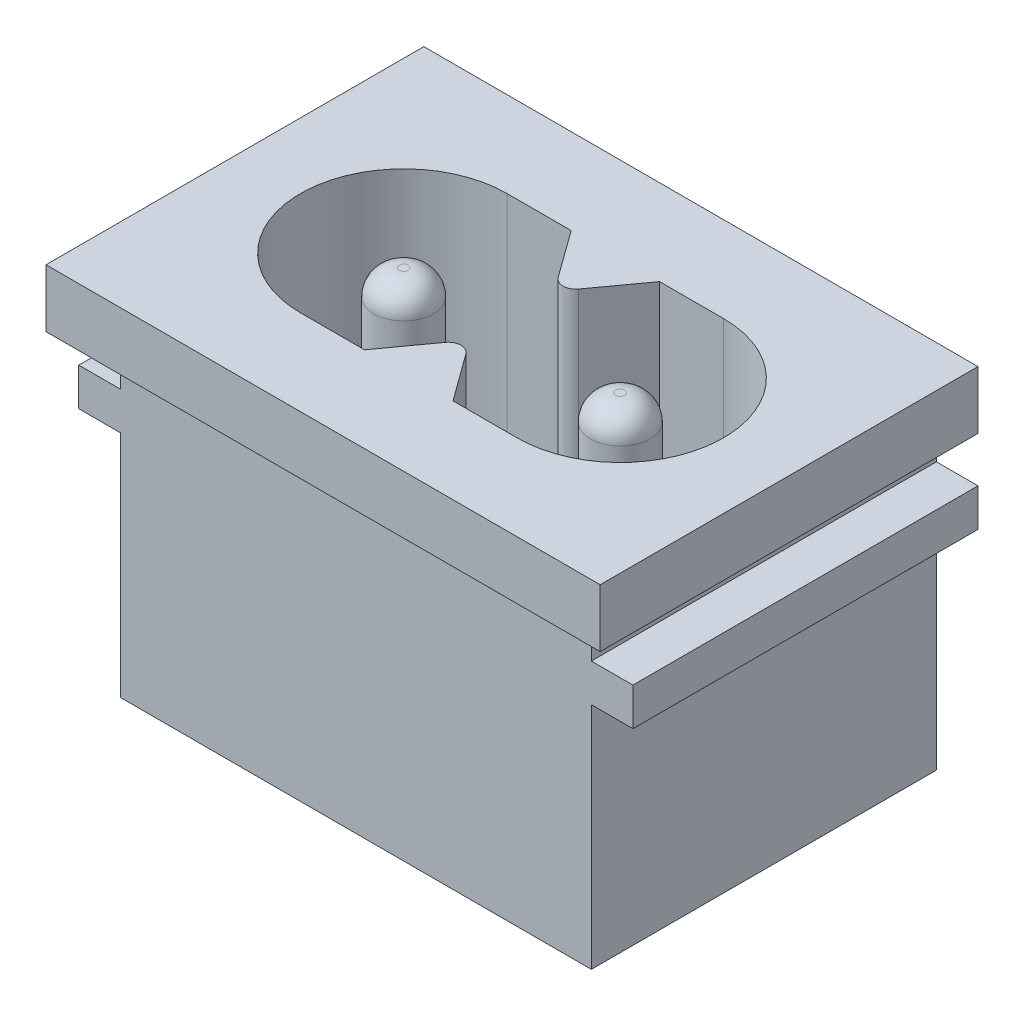
from build123d import *

# Parameters (mm, degrees)
SKETCH_1_W          = 22
SKETCH_1_H          = 15
EXTRUDE_1_DEPTH     = 2.3
SKETCH_2_W          = 18.7
SKETCH_2_H          = 13.7
EXTRUDE_2_DEPTH     = 12.4
SKETCH_3_W          = 13.7
SKETCH_3_H          = 1.5
EXTRUDE_3_DEPTH     = 1.65
SKETCH_4_W          = 13.7
SKETCH_4_H          = 1.5
EXTRUDE_4_DEPTH     = 1.65
CUT_EXTRUDE_1_DEPTH = 10
SKETCH_5_R          = 1.18
EXTRUDE_5_DEPTH     = 9.5
FILLET_6_R          = 1


with BuildPart() as part:
    # 草图1 → 凸台-拉伸1 (new body)
    with BuildSketch(Plane(origin=(0, 0, 0), x_dir=(1, 0, 0), z_dir=(0, 1, 0))):
        Rectangle(SKETCH_1_W, SKETCH_1_H)
    extrude(amount=EXTRUDE_1_DEPTH)

    # 草图2 → 凸台-拉伸2 (add)
    with BuildSketch(Plane.XZ):
        with Locations((0, -0.65)):
            Rectangle(SKETCH_2_W, SKETCH_2_H)
    extrude(amount=EXTRUDE_2_DEPTH)

    # 草图3 → 凸台-拉伸3 (add)
    with BuildSketch(Plane.ZY.offset(9.35)):
        with Locations((-0.65, -2.55)):
            Rectangle(SKETCH_3_W, SKETCH_3_H)
    extrude(amount=EXTRUDE_3_DEPTH)

    # 草图4 → 凸台-拉伸4 (add)
    with BuildSketch(Plane(origin=(9.35, 0, 0), x_dir=(0, 0, -1), z_dir=(1, 0, 0))):
        with Locations((0.65, -2.55)):
            Rectangle(SKETCH_4_W, SKETCH_4_H)
    extrude(amount=EXTRUDE_4_DEPTH)

    # 草图6 → 切除-拉伸1 (cut)
    with BuildSketch(Plane(origin=(0, 2.3, 0), x_dir=(1, 0, 0), z_dir=(0, 1, 0))):
        with BuildLine():
            Line((0.405473154, -2.237773908), (1.757477388, -4.1))
            Line((1.757477388, -4.1), (4.3, -4.1))
            ThreePointArc((4.3, -4.1), (8.4, 0), (4.3, 4.1))
            Line((4.3, 4.1), (1.757477388, 4.1))
            Line((1.757477388, 4.1), (0.405473154, 2.237773908))
            ThreePointArc((0.405473154, 2.237773908), (0.000356772, 2.031527095), (-0.404340983, 2.238594131))
            Line((-0.404340983, 2.238594131), (-1.75, 4.1))
            Line((-1.75, 4.1), (-4.3, 4.1))
            ThreePointArc((-4.3, 4.1), (-8.4, 0), (-4.3, -4.1))
            Line((-4.3, -4.1), (-1.75, -4.1))
            Line((-1.75, -4.1), (-0.404340983, -2.238594131))
            ThreePointArc((-0.404340983, -2.238594131), (0.000356772, -2.031527095), (0.405473154, -2.237773908))
        make_face()
    extrude(amount=-CUT_EXTRUDE_1_DEPTH, mode=Mode.SUBTRACT)

    # 草图5 → 凸台-拉伸5 (add)
    with BuildSketch(Plane(origin=(0, -7.7, 0), x_dir=(1, 0, 0), z_dir=(0, 1, 0))):
        with Locations((-4.3, 0)):
            Circle(SKETCH_5_R)
        with Locations((4.3, 0)):
            Circle(SKETCH_5_R)
    extrude(amount=EXTRUDE_5_DEPTH)

    # 圆角6
    fillet_6_edges = [part.edges().sort_by_distance(p)[0] for p in [
        (-5.48, 1.8, 0),
        (3.12, 1.8, 0),
    ]]
    fillet(fillet_6_edges, radius=FILLET_6_R)


solid = part.part
